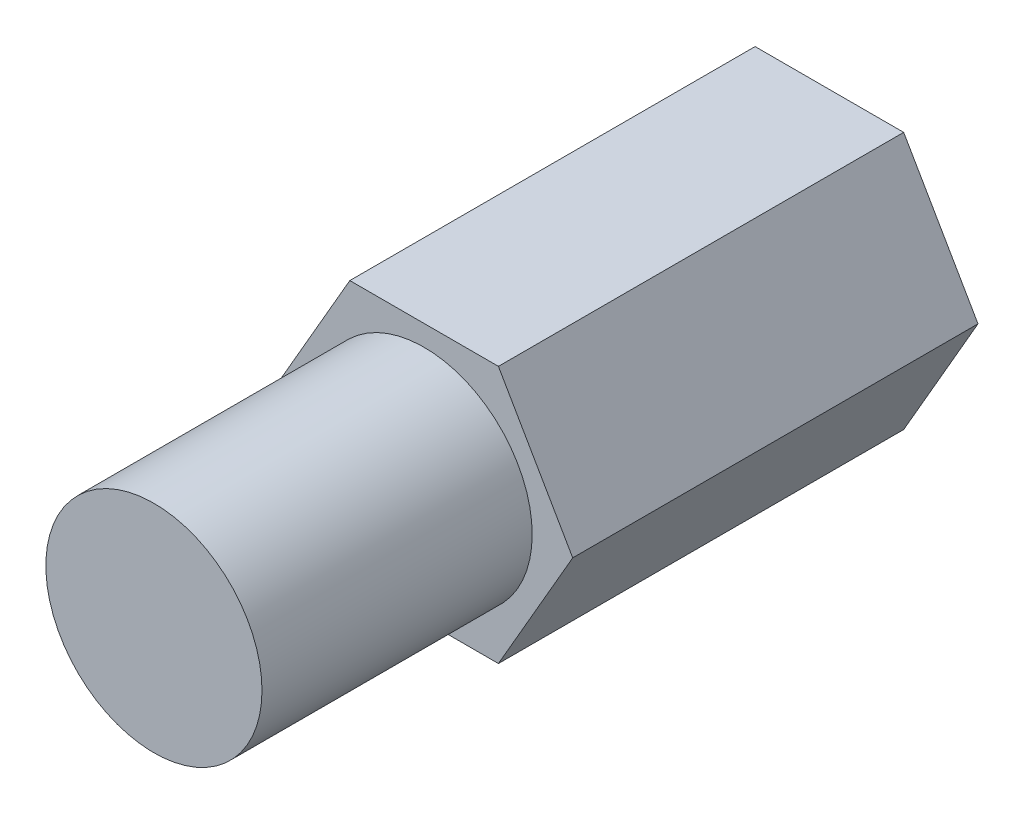
from build123d import *

# Parameters (mm, degrees)
BOSS_EXTRUDE1_DEPTH = 15
SKETCH2_R           = 4
BOSS_EXTRUDE2_DEPTH = 10


with BuildPart() as part:
    # Sketch1 → Boss-Extrude1 (new body)
    with BuildSketch(Plane.XY):
        Polygon((-5.5, 0), (-2.75, -4.763139721), (2.75, -4.763139721), (5.5, 0), (2.75, 4.763139721), (-2.75, 4.763139721), align=None)
    extrude(amount=BOSS_EXTRUDE1_DEPTH)

    # Sketch2 → Boss-Extrude2 (add)
    with BuildSketch(Plane.XY.offset(15)):
        Circle(SKETCH2_R)
    extrude(amount=BOSS_EXTRUDE2_DEPTH)


solid = part.part
